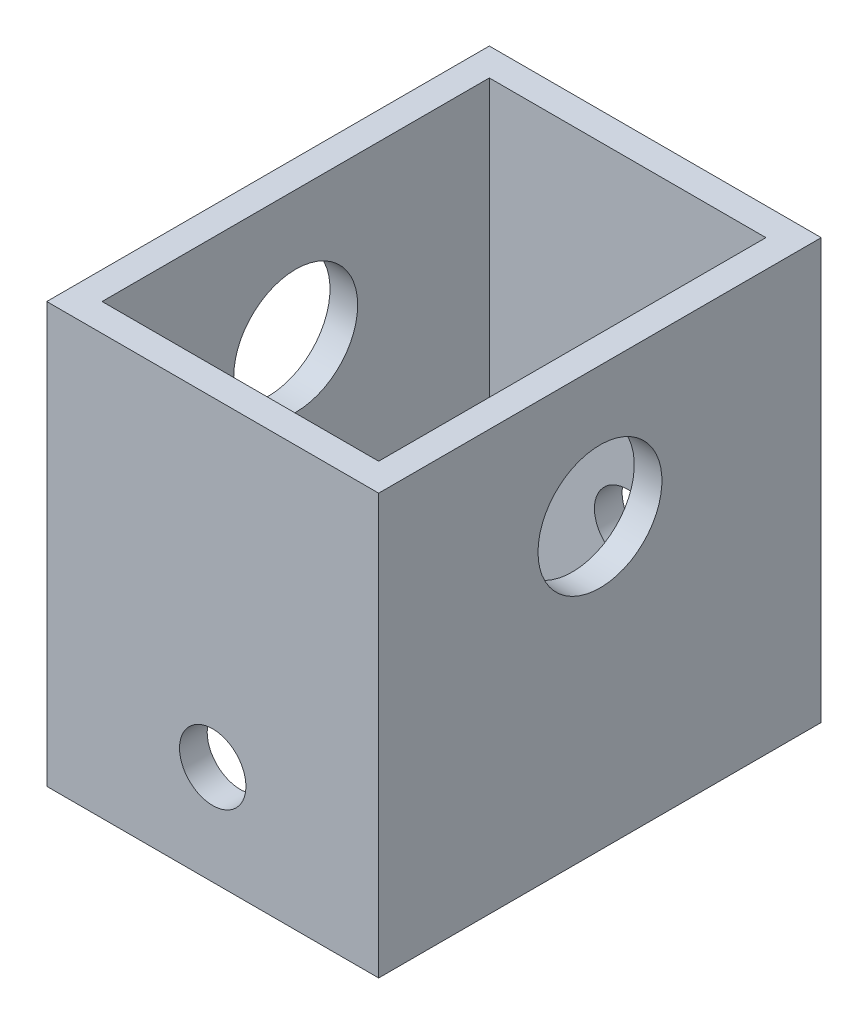
from build123d import *

# Parameters (mm, degrees)
SKETCH2_W           = 76.2
SKETCH2_H           = 101.6
SKETCH2_W_2         = 63.5
SKETCH2_H_2         = 88.9
EXTRUDE_THIN1_DEPTH = 96.393
SKETCH3_R           = 7.62
CUT_EXTRUDE1_DEPTH  = 102.6
SKETCH4_R           = 14.224
CUT_EXTRUDE2_DEPTH  = 77.2


with BuildPart() as part:
    # Sketch2 → Extrude-Thin1 (new body)
    with BuildSketch(Plane(origin=(0, 0, 0), x_dir=(1, 0, 0), z_dir=(0, 1, 0))):
        Rectangle(SKETCH2_W, SKETCH2_H)
        Rectangle(SKETCH2_W_2, SKETCH2_H_2, mode=Mode.SUBTRACT)
    extrude(amount=EXTRUDE_THIN1_DEPTH)

    # Sketch3 → Cut-Extrude1 (cut, through all)
    with BuildSketch(Plane(origin=(0, 0, -50.8), x_dir=(-1, 0, 0), z_dir=(0, 0, -1))):
        with Locations((0, 22.86)):
            Circle(SKETCH3_R)
    extrude(amount=-CUT_EXTRUDE1_DEPTH, mode=Mode.SUBTRACT)

    # Sketch4 → Cut-Extrude2 (cut, through all)
    with BuildSketch(Plane.ZY.offset(38.1)):
        with Locations((0, 66.360000122)):
            Circle(SKETCH4_R)
    extrude(amount=-CUT_EXTRUDE2_DEPTH, mode=Mode.SUBTRACT)


solid = part.part
